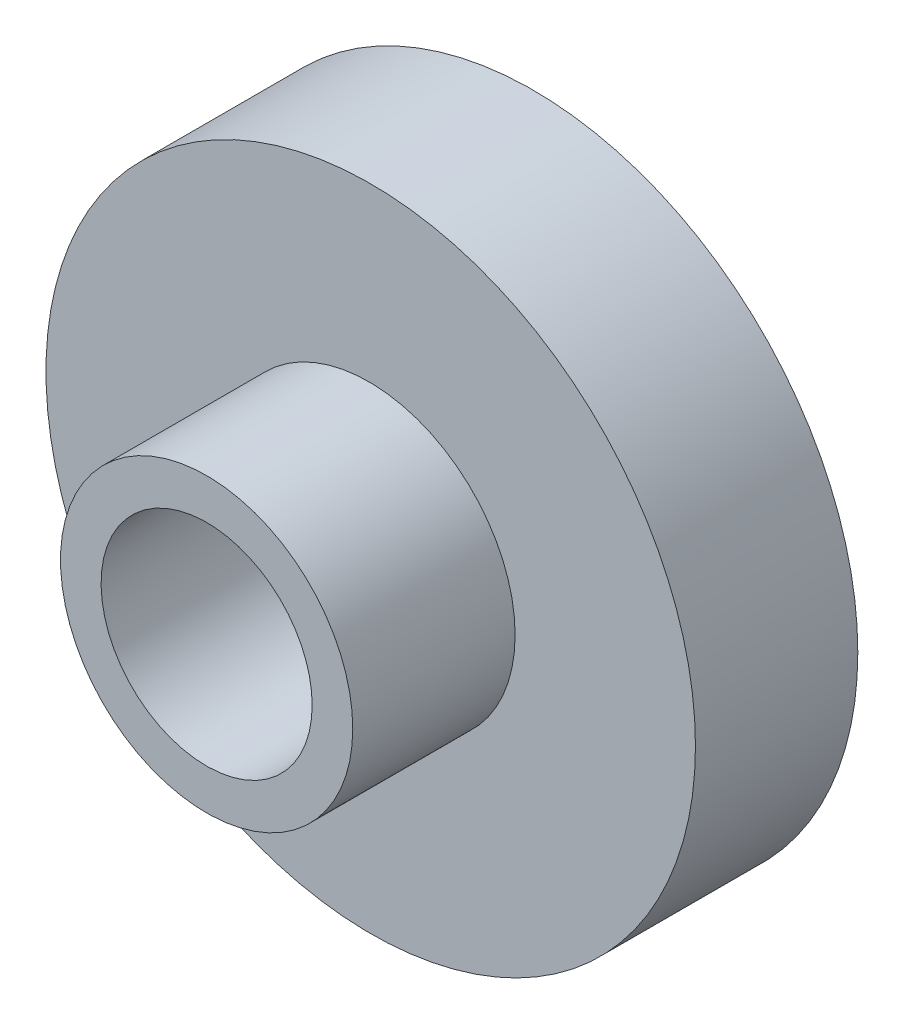
from build123d import *

# Parameters (mm, degrees)
SKETCH1_R           = 10
BOSS_EXTRUDE2_DEPTH = 5
SKETCH2_R           = 4.5
SKETCH2_R_2         = 3.25
BOSS_EXTRUDE3_DEPTH = 5
SKETCH3_R           = 3.450600028
CUT_EXTRUDE1_DEPTH  = 5


with BuildPart() as part:
    # Sketch1 → Boss-Extrude2 (new body)
    with BuildSketch(Plane.XY):
        Circle(SKETCH1_R)
    extrude(amount=BOSS_EXTRUDE2_DEPTH)

    # Sketch2 → Boss-Extrude3 (add)
    with BuildSketch(Plane.XY.offset(5)):
        with Locations((-0.053141413, 0.193433093)):
            Circle(SKETCH2_R)
        with Locations((-0.053141413, 0.193433093)):
            Circle(SKETCH2_R_2, mode=Mode.SUBTRACT)
    extrude(amount=BOSS_EXTRUDE3_DEPTH)

    # Sketch3 → Cut-Extrude1 (cut)
    with BuildSketch(Plane.XY.offset(5)):
        Circle(SKETCH3_R)
    extrude(amount=-CUT_EXTRUDE1_DEPTH, mode=Mode.SUBTRACT)


solid = part.part
